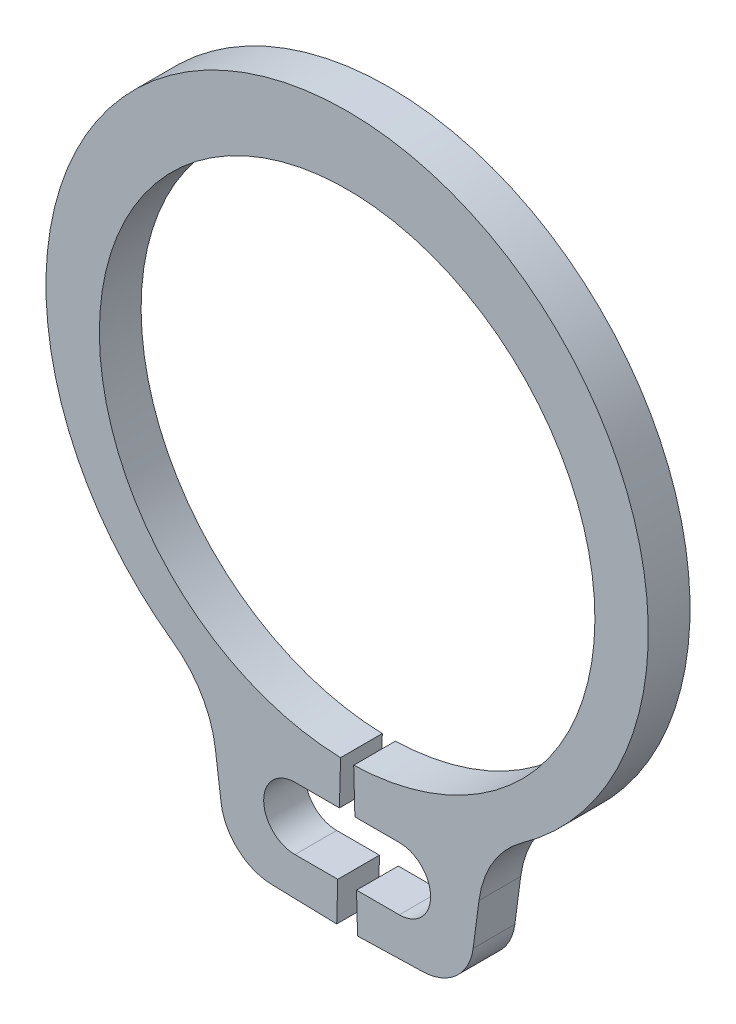
from build123d import *

# Parameters (mm, degrees)
BODYSKE_R   = 0.3
BODY_DEPTH  = 0.4
NOTSKE_W    = 1
NOTSKE_H    = 0.6
NOTCH_DEPTH = 1.4


with BuildPart() as part:
    # BodySke → Body (new body)
    with BuildSketch(Plane.XY):
        with BuildLine():
            Line((0.062913907, -2.374166557), (0.1, -3.773675264))
            Line((0.1, -3.773675264), (0.725313694, -3.757104848))
            ThreePointArc((0.725313694, -3.757104848), (1.046692153, -3.628800321), (1.207791092, -3.322543406))
            Line((1.207791092, -3.322543406), (1.26381232, -2.897019935))
            ThreePointArc((1.26381232, -2.897019935), (1.3982129, -2.512352239), (1.674947292, -2.213268924))
            ThreePointArc((1.674947292, -2.213268924), (0, 3.025), (-1.674947292, -2.213268924))
            ThreePointArc((-1.674947292, -2.213268924), (-1.3982129, -2.512352239), (-1.26381232, -2.897019935))
            Line((-1.26381232, -2.897019935), (-1.207791092, -3.322543406))
            ThreePointArc((-1.207791092, -3.322543406), (-1.046692153, -3.628800321), (-0.725313694, -3.757104848))
            Line((-0.725313694, -3.757104848), (-0.1, -3.773675264))
            Line((-0.1, -3.773675264), (-0.062913907, -2.374166557))
            ThreePointArc((-0.062913907, -2.374166557), (0, 2.375), (0.062913907, -2.374166557))
        make_face()
        with Locations((0.5, -3.097403146)):
            Circle(BODYSKE_R, mode=Mode.SUBTRACT)
        with Locations((-0.5, -3.097403146)):
            Circle(BODYSKE_R, mode=Mode.SUBTRACT)
    extrude(amount=-BODY_DEPTH)

    # NotSke → Notch (cut, through all)
    with BuildSketch(Plane.XY):
        with Locations((0, -3.097403146)):
            Rectangle(NOTSKE_W, NOTSKE_H)
    extrude(amount=-NOTCH_DEPTH, mode=Mode.SUBTRACT)


solid = part.part
